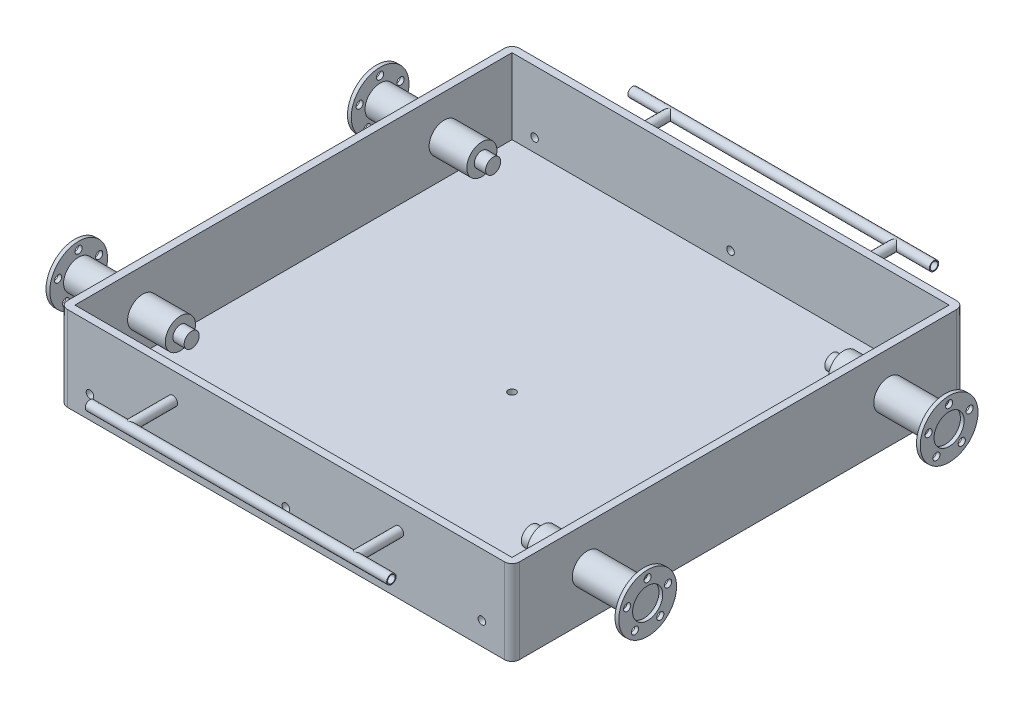
from build123d import *

# Parameters (mm, degrees)
SKETCH1_W                  = 1160
SKETCH1_H                  = 1160
BOSS_EXTRUDE1_DEPTH        = 200
SKETCH2_W                  = 1200
SKETCH2_H                  = 25
BOSS_EXTRUDE2_DEPTH        = 1200
CUT_EXTRUDE1_DEPTH         = 300
CUT_EXTRUDE2_DEPTH         = 300
CUT_EXTRUDE3_DEPTH         = 300
CUT_EXTRUDE4_DEPTH         = 300
SKETCH13_R                 = 20
CUT_EXTRUDE8_DEPTH         = 1357.465996625
SKETCH13_3_R               = 40
SKETCH13_3_R_2             = 20
BOSS_EXTRUDE7_DEPTH        = 150
BOSS_EXTRUDE7_DEPTH_BACK   = 120
SKETCH14_R                 = 76.655
SKETCH14_R_2               = 40
BOSS_EXTRUDE8_DEPTH        = 10
SKETCH15_R                 = 9.525
CUT_EXTRUDE9_DEPTH         = 10
SKETCH18_R                 = 76.655
SKETCH18_R_2               = 40
BOSS_EXTRUDE9_DEPTH        = 10
SKETCH19_R                 = 9.525
CUT_EXTRUDE11_DEPTH        = 10
SKETCH20_R                 = 40
SKETCH20_R_2               = 20
BOSS_EXTRUDE10_DEPTH       = 150
BOSS_EXTRUDE10_DEPTH_BACK  = 120
SKETCH21_R                 = 76.655
SKETCH21_R_2               = 9.525
SKETCH21_R_3               = 40
BOSS_EXTRUDE11_DEPTH       = 10
BOSS_EXTRUDE11_2_DEPTH     = 10
SKETCH22_R                 = 20
BOSS_EXTRUDE12_DEPTH       = 300
SKETCH23_R                 = 20
BOSS_EXTRUDE13_DEPTH       = 300
SKETCH24_R                 = 25.26339589
SKETCH24_R_2               = 20
BOSS_EXTRUDE14_DEPTH       = 300
SKETCH114_R                = 12.5
SKETCH114_R_2              = 10.1
ROUND_END_25_X_2_4_1_DEPTH = 800
BOSS_EXTRUDE15_REACH       = 1436.434
BOSS_EXTRUDE15_END_RADIUS  = 12.5
SKETCH115_R                = 12.5
SKETCH117_R                = 12.5
SKETCH117_R_2              = 10.1
ROUND_END_25_X_2_4_2_DEPTH = 800
BOSS_EXTRUDE16_REACH       = 1548.983
BOSS_EXTRUDE16_END_RADIUS  = 12.5
SKETCH118_R                = 12.5
SKETCH119_R                = 10
CUT_EXTRUDE12_DEPTH        = 1242
SKETCH120_R                = 10
CUT_EXTRUDE13_DEPTH        = 25


with BuildPart() as part:
    # Sketch1 → Boss-Extrude1 (new body)
    with BuildSketch(Plane(origin=(0, 0, 0), x_dir=(1, 0, 0), z_dir=(0, 1, 0))):
        with BuildLine():
            Line((-580, 600), (580, 600))
            ThreePointArc((580, 600), (594.142135624, 594.142135624), (600, 580))
            Line((600, 580), (600, -580))
            ThreePointArc((600, -580), (594.142135624, -594.142135624), (580, -600))
            Line((580, -600), (-580, -600))
            ThreePointArc((-580, -600), (-594.142135624, -594.142135624), (-600, -580))
            Line((-600, -580), (-600, 580))
            ThreePointArc((-600, 580), (-594.142135624, 594.142135624), (-580, 600))
        make_face()
        Rectangle(SKETCH1_W, SKETCH1_H, mode=Mode.SUBTRACT)
    extrude(amount=BOSS_EXTRUDE1_DEPTH)

    # Sketch2 → Boss-Extrude2 (add)
    with BuildSketch(Plane.ZY.offset(600)):
        with Locations((0, -12.5)):
            Rectangle(SKETCH2_W, SKETCH2_H)
    extrude(amount=-BOSS_EXTRUDE2_DEPTH)

    # Sketch5 → Cut-Extrude1 (cut)
    with BuildSketch(Plane(origin=(0, 0, 0), x_dir=(1, 0, 0), z_dir=(0, 1, 0))):
        with BuildLine():
            Line((600, -580), (600, -600))
            Line((600, -600), (580, -600))
            ThreePointArc((580, -600), (594.142135624, -594.142135624), (600, -580))
        make_face()
    extrude(amount=-CUT_EXTRUDE1_DEPTH, mode=Mode.SUBTRACT)

    # Sketch6 → Cut-Extrude2 (cut)
    with BuildSketch(Plane(origin=(0, 0, 0), x_dir=(1, 0, 0), z_dir=(0, 1, 0))):
        with BuildLine():
            Line((-600, -580), (-600, -600))
            Line((-600, -600), (-580, -600))
            ThreePointArc((-580, -600), (-594.142135624, -594.142135624), (-600, -580))
        make_face()
    extrude(amount=-CUT_EXTRUDE2_DEPTH, mode=Mode.SUBTRACT)

    # Sketch7 → Cut-Extrude3 (cut)
    with BuildSketch(Plane(origin=(0, 0, 0), x_dir=(1, 0, 0), z_dir=(0, 1, 0))):
        with BuildLine():
            Line((600, 580), (600, 600))
            Line((600, 600), (580, 600))
            ThreePointArc((580, 600), (594.142135624, 594.142135624), (600, 580))
        make_face()
    extrude(amount=-CUT_EXTRUDE3_DEPTH, mode=Mode.SUBTRACT)

    # Sketch8 → Cut-Extrude4 (cut)
    with BuildSketch(Plane(origin=(0, 0, 0), x_dir=(1, 0, 0), z_dir=(0, 1, 0))):
        with BuildLine():
            Line((-580, 600), (-600, 600))
            Line((-600, 600), (-600, 580))
            ThreePointArc((-600, 580), (-594.142135624, 594.142135624), (-580, 600))
        make_face()
    extrude(amount=-CUT_EXTRUDE4_DEPTH, mode=Mode.SUBTRACT)

    # Sketch13 → Cut-Extrude8 (cut, through all)
    with BuildSketch(Plane(origin=(600, 0, 0), x_dir=(0, 0, -1), z_dir=(1, 0, 0))):
        with Locations((-400, 95)):
            Circle(SKETCH13_R)
        with Locations((400, 95)):
            Circle(SKETCH13_R)
    extrude(amount=-CUT_EXTRUDE8_DEPTH, mode=Mode.SUBTRACT)

    # Sketch13_3 → Boss-Extrude7 (add, two sides)
    with BuildSketch(Plane(origin=(600, 0, 0), x_dir=(0, 0, -1), z_dir=(1, 0, 0))) as boss_extrude7_sk:
        with Locations((-400, 95)):
            Circle(SKETCH13_3_R)
        with Locations((-400, 95)):
            Circle(SKETCH13_3_R_2, mode=Mode.SUBTRACT)
        with Locations((400, 95)):
            Circle(SKETCH13_3_R)
        with Locations((400, 95)):
            Circle(SKETCH13_3_R_2, mode=Mode.SUBTRACT)
    extrude(amount=BOSS_EXTRUDE7_DEPTH)
    extrude(boss_extrude7_sk.sketch, amount=-BOSS_EXTRUDE7_DEPTH_BACK)

    # Sketch20 → Boss-Extrude10 (add, two sides)
    with BuildSketch(Plane.ZY.offset(600)) as boss_extrude10_sk:
        with Locations(Location((400, 95, 0), (0, 0, 180))):
            Circle(SKETCH20_R)
        with Locations(Location((400, 95, 0), (0, 0, 180))):
            Circle(SKETCH20_R_2, mode=Mode.SUBTRACT)
        with Locations(Location((-400, 95, 0), (0, 0, 180))):
            Circle(SKETCH20_R)
        with Locations(Location((-400, 95, 0), (0, 0, 180))):
            Circle(SKETCH20_R_2, mode=Mode.SUBTRACT)
    extrude(amount=BOSS_EXTRUDE10_DEPTH)
    extrude(boss_extrude10_sk.sketch, amount=-BOSS_EXTRUDE10_DEPTH_BACK)

    # Sketch22 → Boss-Extrude12 (add)
    with BuildSketch(Plane.ZY.offset(750)):
        with Locations(Location((-400, 95, 0), (0, 0, 180))):
            Circle(SKETCH22_R)
    extrude(amount=-BOSS_EXTRUDE12_DEPTH)

    # Sketch23 → Boss-Extrude13 (add)
    with BuildSketch(Plane.ZY.offset(750)):
        with Locations(Location((400, 95, 0), (0, 0, 180))):
            Circle(SKETCH23_R)
    extrude(amount=-BOSS_EXTRUDE13_DEPTH)

    # Sketch24 → Boss-Extrude14 (add)
    with BuildSketch(Plane(origin=(750, 0, 0), x_dir=(0, 0, -1), z_dir=(1, 0, 0))):
        with Locations((-400, 95)):
            Circle(SKETCH24_R)
        with Locations(Location((400, 95, 0), (0, 0, 180))):
            Circle(SKETCH24_R_2)
    extrude(amount=-BOSS_EXTRUDE14_DEPTH)

    # Sketch119 → Cut-Extrude12 (cut)
    with BuildSketch(Plane.XY.offset(600)):
        with Locations((0, 35)):
            Circle(SKETCH119_R)
        with Locations((-520, 35)):
            Circle(SKETCH119_R)
        with Locations((520, 35)):
            Circle(SKETCH119_R)
    extrude(amount=-CUT_EXTRUDE12_DEPTH, mode=Mode.SUBTRACT)

    # Sketch120 → Cut-Extrude13 (cut)
    with BuildSketch(Plane.XZ.offset(25)):
        with Locations(Location((0, 0, 0), (0, 0, 270))):
            Circle(SKETCH120_R)
    extrude(amount=-CUT_EXTRUDE13_DEPTH, mode=Mode.SUBTRACT)


with BuildPart() as body_2:
    # Sketch14 → Boss-Extrude8 (new body)
    with BuildSketch(Plane(origin=(750, 0, 0), x_dir=(0, 0, -1), z_dir=(1, 0, 0))):
        with Locations((-400, 95)):
            Circle(SKETCH14_R)
        with Locations((-400, 95)):
            Circle(SKETCH14_R_2, mode=Mode.SUBTRACT)
    extrude(amount=BOSS_EXTRUDE8_DEPTH)

    # Sketch15 → Cut-Extrude9 (cut)
    with BuildSketch(Plane(origin=(760, 0, 0), x_dir=(0, 0, -1), z_dir=(1, 0, 0))):
        with Locations((-400, 152.15)):
            Circle(SKETCH15_R)
        with Locations((400.614525981, 1139.801358827)):
            Circle(SKETCH15_R)
        with Locations((1587.330281093, 683.572751247)):
            Circle(SKETCH15_R)
        with Locations((1520.146426756, -586.043393704)):
            Circle(SKETCH15_R)
        with Locations((291.908766169, -914.48071637)):
            Circle(SKETCH15_R)
        with Locations((-345.647120094, 112.660321229)):
            Circle(SKETCH15_R)
        with Locations((-366.408072831, 48.764678771)):
            Circle(SKETCH15_R)
        with Locations((-433.591927169, 48.764678771)):
            Circle(SKETCH15_R)
        with Locations((-454.352879906, 112.660321229)):
            Circle(SKETCH15_R)
    extrude(amount=-CUT_EXTRUDE9_DEPTH, mode=Mode.SUBTRACT)


with BuildPart() as body_3:
    # Sketch18 → Boss-Extrude9 (new body)
    with BuildSketch(Plane(origin=(750, 0, 0), x_dir=(0, 0, -1), z_dir=(1, 0, 0))):
        with Locations((400, 95)):
            Circle(SKETCH18_R)
        with Locations((400, 95)):
            Circle(SKETCH18_R_2, mode=Mode.SUBTRACT)
    extrude(amount=BOSS_EXTRUDE9_DEPTH)

    # Sketch19 → Cut-Extrude11 (cut)
    with BuildSketch(Plane(origin=(760, 0, 0), x_dir=(0, 0, -1), z_dir=(1, 0, 0))):
        with Locations((400, 152.155)):
            Circle(SKETCH19_R)
        with Locations((454.357635189, 112.661866314)):
            Circle(SKETCH19_R)
        with Locations((433.594866095, 48.760633686)):
            Circle(SKETCH19_R)
        with Locations((366.405133905, 48.760633686)):
            Circle(SKETCH19_R)
        with Locations((345.642364811, 112.661866314)):
            Circle(SKETCH19_R)
    extrude(amount=-CUT_EXTRUDE11_DEPTH, mode=Mode.SUBTRACT)


with BuildPart() as body_4:
    # Sketch21 → Boss-Extrude11 (new body)
    with BuildSketch(Plane.ZY.offset(750)):
        with Locations((-400, 95)):
            Circle(SKETCH21_R)
        with Locations((-400, 152.15)):
            Circle(SKETCH21_R_2, mode=Mode.SUBTRACT)
        with Locations((-345.647120094, 112.660321229)):
            Circle(SKETCH21_R_2, mode=Mode.SUBTRACT)
        with Locations((-366.408072831, 48.764678771)):
            Circle(SKETCH21_R_2, mode=Mode.SUBTRACT)
        with Locations((-433.591927169, 48.764678771)):
            Circle(SKETCH21_R_2, mode=Mode.SUBTRACT)
        with Locations((-454.352879906, 112.660321229)):
            Circle(SKETCH21_R_2, mode=Mode.SUBTRACT)
        with Locations((-400, 95)):
            Circle(SKETCH21_R_3, mode=Mode.SUBTRACT)
    extrude(amount=BOSS_EXTRUDE11_DEPTH)


with BuildPart() as body_5:
    # Sketch21 → Boss-Extrude11 2 (new body)
    with BuildSketch(Plane.ZY.offset(750)):
        with Locations((400, 95)):
            Circle(SKETCH21_R)
        with Locations((400, 152.15)):
            Circle(SKETCH21_R_2, mode=Mode.SUBTRACT)
        with Locations((454.352879906, 112.660321229)):
            Circle(SKETCH21_R_2, mode=Mode.SUBTRACT)
        with Locations((433.591927169, 48.764678771)):
            Circle(SKETCH21_R_2, mode=Mode.SUBTRACT)
        with Locations((366.408072831, 48.764678771)):
            Circle(SKETCH21_R_2, mode=Mode.SUBTRACT)
        with Locations((345.647120094, 112.660321229)):
            Circle(SKETCH21_R_2, mode=Mode.SUBTRACT)
        with Locations((400, 95)):
            Circle(SKETCH21_R_3, mode=Mode.SUBTRACT)
    extrude(amount=BOSS_EXTRUDE11_2_DEPTH)


with BuildPart() as body_6:
    # Sketch114 → Round end 25 X 2.4_1 (new body)
    with BuildSketch(Plane(origin=(400, 130, -720), x_dir=(0, 1, 0), z_dir=(-1, 0, 0))):
        Circle(SKETCH114_R)
        Circle(SKETCH114_R_2, mode=Mode.SUBTRACT)
    extrude(amount=ROUND_END_25_X_2_4_1_DEPTH)


with BuildPart() as body_7:
    # Boss-Extrude15: up to this cylinder (the profile starts outside it)
    boss_extrude15_end = Plane(origin=(0, 130, -720), z_dir=(1, 0, 0)) * Cylinder(BOSS_EXTRUDE15_END_RADIUS, 3498.868, mode=Mode.PRIVATE)
    # Sketch115 → Boss-Extrude15 (new, up to the surface)
    with BuildSketch(Plane(origin=(0, 0, -600), x_dir=(-1, 0, 0), z_dir=(0, 0, -1)), mode=Mode.PRIVATE) as boss_extrude15_sk1:
        with Locations(Location((-300, 130, 0), (0, 0, 90))):
            Circle(SKETCH115_R)
    boss_extrude15_tool1 = extrude(boss_extrude15_sk1.sketch, amount=BOSS_EXTRUDE15_REACH, mode=Mode.PRIVATE) - boss_extrude15_end
    add(boss_extrude15_tool1.solids().sort_by_distance((300, 130, -600))[0])
    # Sketch115 → Boss-Extrude15 (new, up to the surface)
    with BuildSketch(Plane(origin=(0, 0, -600), x_dir=(-1, 0, 0), z_dir=(0, 0, -1)), mode=Mode.PRIVATE) as boss_extrude15_sk2:
        with Locations(Location((300, 130, 0), (0, 0, 90))):
            Circle(SKETCH115_R)
    boss_extrude15_tool2 = extrude(boss_extrude15_sk2.sketch, amount=BOSS_EXTRUDE15_REACH, mode=Mode.PRIVATE) - boss_extrude15_end
    add(boss_extrude15_tool2.solids().sort_by_distance((-300, 130, -600))[0])


with BuildPart() as body_8:
    # Sketch117 → Round end 25 X 2.4_2 (new body)
    with BuildSketch(Plane(origin=(-400, 130, 720), x_dir=(0, 1, 0), z_dir=(1, 0, 0))):
        Circle(SKETCH117_R)
        Circle(SKETCH117_R_2, mode=Mode.SUBTRACT)
    extrude(amount=ROUND_END_25_X_2_4_2_DEPTH)


with BuildPart() as body_9:
    # Boss-Extrude16: up to this cylinder (the profile starts outside it)
    boss_extrude16_end = Plane(origin=(0, 130, 720), z_dir=(-1, 0, 0)) * Cylinder(BOSS_EXTRUDE16_END_RADIUS, 3723.966, mode=Mode.PRIVATE)
    # Sketch118 → Boss-Extrude16 (new, up to the surface)
    with BuildSketch(Plane.XY.offset(600), mode=Mode.PRIVATE) as boss_extrude16_sk1:
        with Locations(Location((-300, 130, 0), (0, 0, 90))):
            Circle(SKETCH118_R)
    boss_extrude16_tool1 = extrude(boss_extrude16_sk1.sketch, amount=BOSS_EXTRUDE16_REACH, mode=Mode.PRIVATE) - boss_extrude16_end
    add(boss_extrude16_tool1.solids().sort_by_distance((-300, 130, 600))[0])
    # Sketch118 → Boss-Extrude16 (new, up to the surface)
    with BuildSketch(Plane.XY.offset(600), mode=Mode.PRIVATE) as boss_extrude16_sk2:
        with Locations(Location((300, 130, 0), (0, 0, 90))):
            Circle(SKETCH118_R)
    boss_extrude16_tool2 = extrude(boss_extrude16_sk2.sketch, amount=BOSS_EXTRUDE16_REACH, mode=Mode.PRIVATE) - boss_extrude16_end
    add(boss_extrude16_tool2.solids().sort_by_distance((300, 130, 600))[0])


solid = Compound([part.part, body_2.part, body_3.part, body_4.part, body_5.part, body_6.part, body_7.part, body_8.part, body_9.part])
